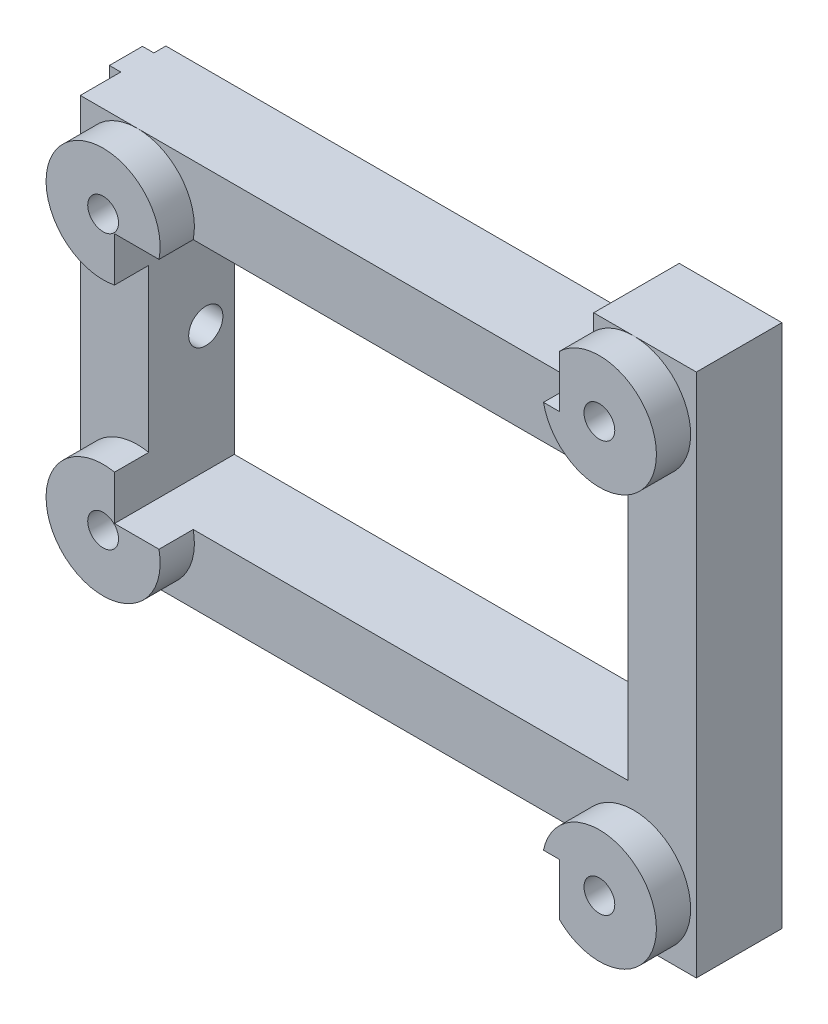
from build123d import *

# Parameters (mm, degrees)
ESQUISSE1_W             = 54
ESQUISSE1_H             = 46
MAIN_DEPTH              = 7.5
ESQUISSE2_R             = 1.35
USBFIXHOLES_DEPTH       = 8.5
ESQUISSE3_R             = 5
CIRCLESUPPORT_DEPTH     = 3
ESQUISSE4_W             = 45
ESQUISSE4_H             = 10.5
SIDECUTOFF_DEPTH        = 6
ESQUISSE6_W             = 45
ESQUISSE6_H             = 10.5
SIDELEFTCUTOFF_DEPTH    = 6
ESQUISSE7_W             = 2.9
ESQUISSE7_H             = 34
MAKERBEAMFIXSHAFT_DEPTH = 1
ESQUISSE10_W            = 42
ESQUISSE10_H            = 22
CENTRALHOLE_DEPTH       = 1
CENTRALHOLE_DEPTH_BACK  = 11.5
VERTICALFIXHOLE_REACH   = 57
ESQUISSE8_R             = 1.5
ESQUISSE11_R            = 1.35
USBFIXHOLES2_DEPTH      = 4


with BuildPart() as part:
    # Esquisse1 → Main (new body)
    with BuildSketch(Plane.XY):
        Rectangle(ESQUISSE1_W, ESQUISSE1_H)
    extrude(amount=MAIN_DEPTH)

    # Esquisse2 → UsbFixHoles (cut, through all)
    with BuildSketch(Plane.XY.offset(7.5)):
        with Locations((-22, -12)):
            Circle(ESQUISSE2_R)
        with Locations((-22, 12)):
            Circle(ESQUISSE2_R)
        with Locations((21.5, 18)):
            Circle(ESQUISSE2_R)
        with Locations((21.5, -18)):
            Circle(ESQUISSE2_R)
    extrude(amount=-USBFIXHOLES_DEPTH, mode=Mode.SUBTRACT)

    # Esquisse3 → CircleSupport (add)
    with BuildSketch(Plane.XY.offset(7.5)):
        with Locations((-22, 12)):
            Circle(ESQUISSE3_R)
        with Locations((-22, -12)):
            Circle(ESQUISSE3_R)
        with Locations((21.5, -18)):
            Circle(ESQUISSE3_R)
        with Locations((21.5, 18)):
            Circle(ESQUISSE3_R)
    extrude(amount=CIRCLESUPPORT_DEPTH)

    # Esquisse4 → SideCutoff (cut)
    with BuildSketch(Plane.XZ.offset(23)):
        with Locations((-4.5, 5.25)):
            Rectangle(ESQUISSE4_W, ESQUISSE4_H)
    extrude(amount=-SIDECUTOFF_DEPTH, mode=Mode.SUBTRACT)

    # Esquisse6 → SideLeftCutoff (cut)
    with BuildSketch(Plane(origin=(0, 23, 0), x_dir=(1, 0, 0), z_dir=(0, 1, 0))):
        with Locations((-4.5, -5.25)):
            Rectangle(ESQUISSE6_W, ESQUISSE6_H)
    extrude(amount=-SIDELEFTCUTOFF_DEPTH, mode=Mode.SUBTRACT)

    # Esquisse7 → MakerBeamFixShaft (add)
    with BuildSketch(Plane.ZY.offset(27)):
        with Locations((2.5, 0)):
            Rectangle(ESQUISSE7_W, ESQUISSE7_H)
    extrude(amount=MAKERBEAMFIXSHAFT_DEPTH)

    # Esquisse10 → CentralHole (cut, two sides)
    with BuildSketch(Plane.XY.offset(10.5)) as centralhole_sk:
        Rectangle(ESQUISSE10_W, ESQUISSE10_H)
    extrude(amount=CENTRALHOLE_DEPTH, mode=Mode.SUBTRACT)
    extrude(centralhole_sk.sketch, amount=-CENTRALHOLE_DEPTH_BACK, mode=Mode.SUBTRACT)

    # Esquisse8 → VerticalFixHole (cut, up to next)
    with BuildSketch(Plane.ZY.offset(28), mode=Mode.PRIVATE) as verticalfixhole_sk1:
        with Locations((2.5, 0)):
            Circle(ESQUISSE8_R)
    verticalfixhole_tool1 = extrude(verticalfixhole_sk1.sketch, amount=-VERTICALFIXHOLE_REACH, mode=Mode.PRIVATE) & part.part
    add(verticalfixhole_tool1.solids().sort_by_distance((-28, 0, 2.5))[0], mode=Mode.SUBTRACT)

    # Esquisse11 → UsbFixHoles2 (cut, through all)
    with BuildSketch(Plane(origin=(0, 0, 7.5), x_dir=(-1, 0, 0), z_dir=(0, 0, -1))):
        with Locations((-21.5, 18)):
            Circle(ESQUISSE11_R)
        with Locations((22, 12)):
            Circle(ESQUISSE11_R)
        with Locations((22, -12)):
            Circle(ESQUISSE11_R)
        with Locations((-21.5, -18)):
            Circle(ESQUISSE11_R)
    extrude(amount=-USBFIXHOLES2_DEPTH, mode=Mode.SUBTRACT)


solid = part.part
